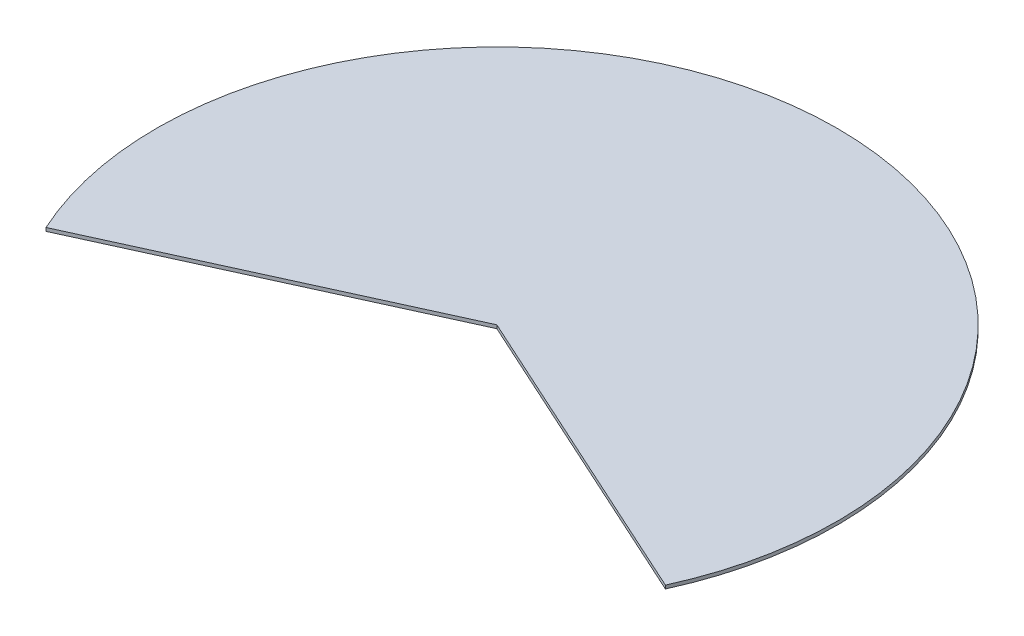
from build123d import *

# Parameters (mm, degrees)
BOSS_EXTRUDE1_DEPTH = 10


with BuildPart() as part:
    # Sketch1 → Boss-Extrude1 (new body)
    with BuildSketch(Plane(origin=(0, 0, 0), x_dir=(1, 0, 0), z_dir=(0, 1, 0))):
        with BuildLine():
            Line((-909.961270877, -414.693242656), (0, 0))
            Line((0, 0), (909.961270877, -414.693242656))
            ThreePointArc((909.961270877, -414.693242656), (0, 1000), (-909.961270877, -414.693242656))
        make_face()
    extrude(amount=BOSS_EXTRUDE1_DEPTH)


solid = part.part
